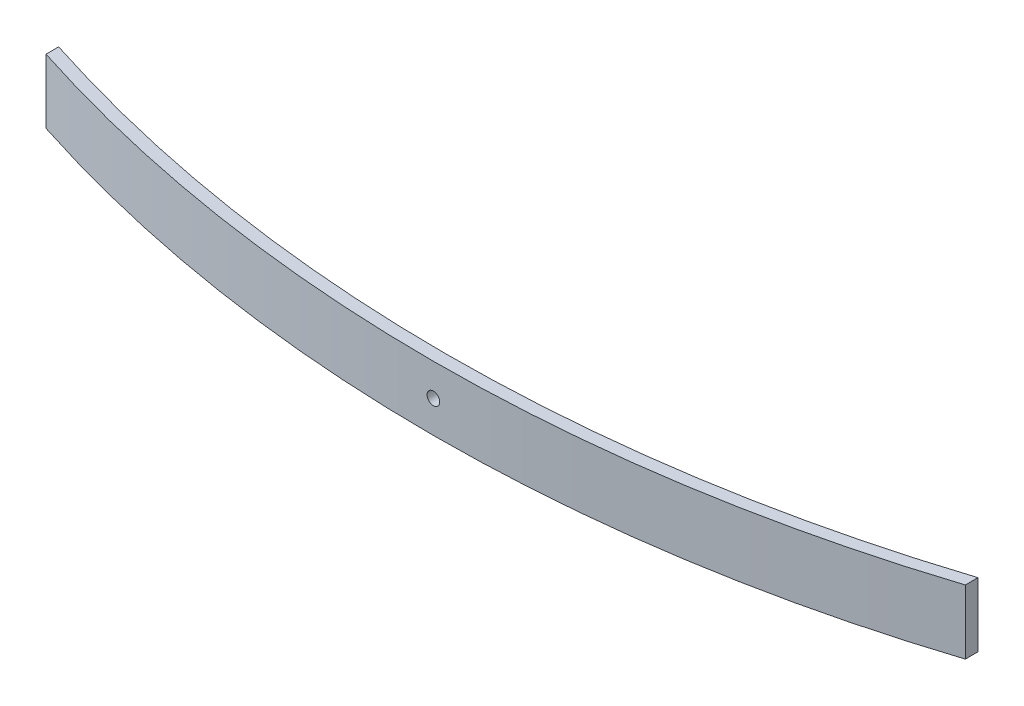
from build123d import *

# Parameters (mm, degrees)
BOSS_EXTRUDE1_DEPTH = 76.2
SKETCH8_R           = 7.5
CUT_EXTRUDE1_DEPTH  = 194


with BuildPart() as part:
    # Sketch1 → Boss-Extrude1 (new body)
    with BuildSketch(Plane(origin=(0, 0, 0), x_dir=(1, 0, 0), z_dir=(0, 1, 0))):
        with BuildLine():
            ThreePointArc((545.021699517, -92.306455218), (0, -178), (-545.021699517, -92.306455218))
            Line((-545.021699517, -92.306455218), (-545.021699517, -107.306455218))
            ThreePointArc((-545.021699517, -107.306455218), (0, -193), (545.021699517, -107.306455218))
            Line((545.021699517, -107.306455218), (545.021699517, -92.306455218))
        make_face()
    extrude(amount=BOSS_EXTRUDE1_DEPTH)

    # Sketch8 → Cut-Extrude1 (cut, through all)
    with BuildSketch(Plane.XY):
        with Locations((0, 38.1)):
            Circle(SKETCH8_R)
    extrude(amount=CUT_EXTRUDE1_DEPTH, mode=Mode.SUBTRACT)


solid = part.part
